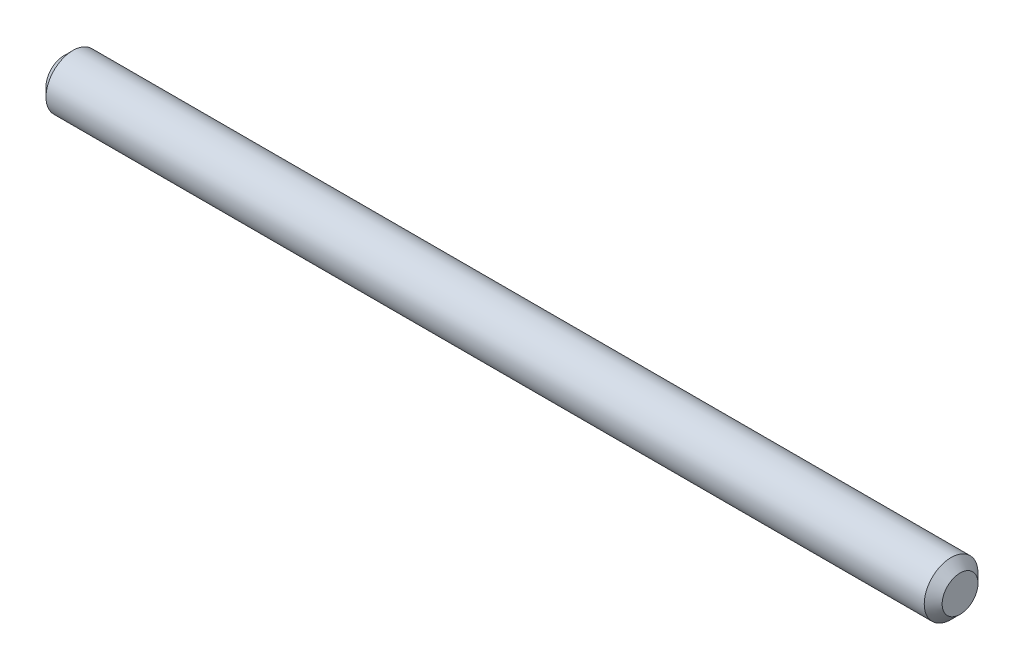
from build123d import *

# Parameters (mm, degrees)
SKETCH1_W     = 50
SKETCH1_H     = 1.5
CHAMFER1_SIZE = 0.5


with BuildPart() as part:
    # Sketch1 → Revolve1 (revolve)
    with BuildSketch(Plane.XY):
        with Locations((25, 0.75)):
            Rectangle(SKETCH1_W, SKETCH1_H)
    revolve(axis=Axis((0, 0, 0), (1, 0, 0)))

    # Chamfer1
    chamfer1_edges = [part.edges().sort_by_distance(p)[0] for p in [
        (50, -1.5, 0),
        (0, -1.5, 0),
    ]]
    chamfer(chamfer1_edges, length=CHAMFER1_SIZE)


solid = part.part
